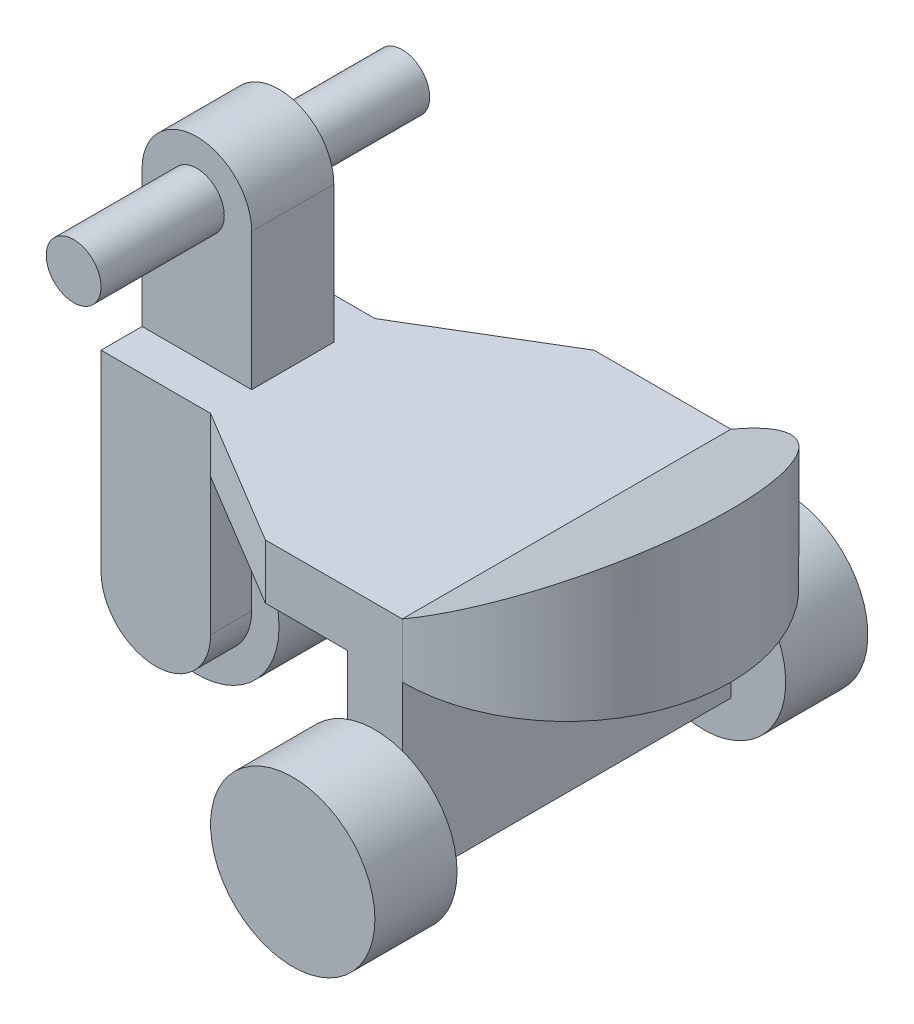
from build123d import *

# Parameters (mm, degrees)
EXTRUDE1_DEPTH       = 20
EXTRUDE2_DEPTH       = 40
CUT_EXTRUDE1_DEPTH   = 60
SKETCH5_W            = 20
SKETCH5_H            = 120
SKETCH5_W_2          = 40
SKETCH5_H_2          = 15
EXTRUDE3_DEPTH       = 50
SKETCH6_W            = 20
SKETCH6_H            = 120
EXTRUDE4_DEPTH       = 15
SKETCH7_R            = 20
EXTRUDE5_DEPTH       = 15
SKETCH8_R            = 20
EXTRUDE6_DEPTH       = 15
SKETCH9_R            = 30
EXTRUDE7_DEPTH       = 30
SKETCH10_R           = 30
EXTRUDE8_DEPTH       = 30
SKETCH12_R           = 30
EXTRUDE9_DEPTH       = 30
SKETCH13_W           = 40
SKETCH13_H           = 30
EXTRUDE10_DEPTH      = 50
EXTRUDE10_DEPTH_BACK = 20
SKETCH14_R           = 20
EXTRUDE12_DEPTH      = 30
SKETCH15_R           = 10
EXTRUDE13_DEPTH      = 45
SKETCH16_R           = 10
EXTRUDE14_DEPTH      = 45


with BuildPart() as part:
    # Sketch1 → Extrude1 (new body)
    with BuildSketch(Plane(origin=(0, 0, 0), x_dir=(1, 0, 0), z_dir=(0, 1, 0))):
        with BuildLine():
            Line((0, -60), (-50, -60))
            Line((-50, -60), (-100, -30))
            Line((-100, -30), (-140, -30))
            Line((-140, -30), (-140, -15))
            Line((-140, -15), (-100, -15))
            Line((-100, -15), (-100, 15))
            Line((-100, 15), (-140, 15))
            Line((-140, 15), (-140, 30))
            Line((-140, 30), (-100, 30))
            Line((-100, 30), (-50, 60))
            Line((-50, 60), (0, 60))
            ThreePointArc((0, 60), (60, 0), (0, -60))
        make_face()
    extrude(amount=EXTRUDE1_DEPTH)

    # Sketch2 → Extrude2 (add)
    with BuildSketch(Plane(origin=(0, 20, 0), x_dir=(-1, 0, 0), z_dir=(0, 1, 0))):
        with BuildLine():
            Line((0, -60), (0, 60))
            ThreePointArc((0, 60), (-60, 0), (0, -60))
        make_face()
    extrude(amount=EXTRUDE2_DEPTH)

    # Sketch4 → Cut-Extrude1 (cut, symmetric)
    with BuildSketch(Plane.XY):
        Polygon((0, 20), (76.102453908, 63.93777225), (55, 100.488294582), (-21.102453908, 56.550522332), align=None)
    extrude(amount=CUT_EXTRUDE1_DEPTH, both=True, mode=Mode.SUBTRACT)

    # Sketch5 → Extrude3 (add)
    with BuildSketch(Plane.XZ):
        with Locations((-10, 0)):
            Rectangle(SKETCH5_W, SKETCH5_H)
        with Locations((-120, 22.5)):
            Rectangle(SKETCH5_W_2, SKETCH5_H_2)
        with Locations((-120, -22.5)):
            Rectangle(SKETCH5_W_2, SKETCH5_H_2)
    extrude(amount=EXTRUDE3_DEPTH)

    # Sketch6 → Extrude4 (add)
    with BuildSketch(Plane.XZ.offset(50)):
        with Locations((-10, 0)):
            Rectangle(SKETCH6_W, SKETCH6_H)
    extrude(amount=EXTRUDE4_DEPTH)

    # Sketch7 → Extrude5 (add)
    with BuildSketch(Plane.XY.offset(30)):
        with Locations((-120, -50)):
            Circle(SKETCH7_R)
    extrude(amount=-EXTRUDE5_DEPTH)

    # Sketch8 → Extrude6 (add)
    with BuildSketch(Plane.XY.offset(-15)):
        with Locations((-120, -50)):
            Circle(SKETCH8_R)
    extrude(amount=-EXTRUDE6_DEPTH)


with BuildPart() as body_2:
    # Sketch9 → Extrude7 (new body)
    with BuildSketch(Plane.XY.offset(60)):
        with Locations((-10, -50)):
            Circle(SKETCH9_R)
    extrude(amount=EXTRUDE7_DEPTH)


with BuildPart() as body_3:
    # Sketch10 → Extrude8 (new body)
    with BuildSketch(Plane(origin=(0, 0, -60), x_dir=(-1, 0, 0), z_dir=(0, 0, -1))):
        with Locations((10, -50)):
            Circle(SKETCH10_R)
    extrude(amount=EXTRUDE8_DEPTH)


with BuildPart() as body_4:
    # Sketch12 → Extrude9 (new body)
    with BuildSketch(Plane.XY.offset(-15)):
        with Locations((-120, -50)):
            Circle(SKETCH12_R)
    extrude(amount=EXTRUDE9_DEPTH)


with BuildPart() as body_5:
    # Sketch13 → Extrude10 (new body, two sides)
    with BuildSketch(Plane(origin=(0, 20, 0), x_dir=(-1, 0, 0), z_dir=(0, 1, 0))) as extrude10_sk:
        with Locations((120, 0)):
            Rectangle(SKETCH13_W, SKETCH13_H)
    extrude(amount=EXTRUDE10_DEPTH)
    extrude(extrude10_sk.sketch, amount=-EXTRUDE10_DEPTH_BACK)


with BuildPart() as body_6:
    # Sketch14 → Extrude12 (new body)
    with BuildSketch(Plane.XY.offset(15)):
        with Locations((-120, 70)):
            Circle(SKETCH14_R)
    extrude(amount=-EXTRUDE12_DEPTH)


with BuildPart() as body_5_1:
    add(body_5.part)

    # Combine1: union body 6
    add(body_6.part)


with BuildPart() as body_6_2:
    # Sketch15 → Extrude13 (new body)
    with BuildSketch(Plane.XY.offset(15)):
        with Locations((-120, 70)):
            Circle(SKETCH15_R)
    extrude(amount=EXTRUDE13_DEPTH)


with BuildPart() as body_7:
    # Sketch16 → Extrude14 (new body)
    with BuildSketch(Plane(origin=(0, 0, -15), x_dir=(-1, 0, 0), z_dir=(0, 0, -1))):
        with Locations((120, 70)):
            Circle(SKETCH16_R)
    extrude(amount=EXTRUDE14_DEPTH)


solid = Compound([part.part, body_2.part, body_3.part, body_4.part, body_5_1.part, body_6_2.part, body_7.part])
